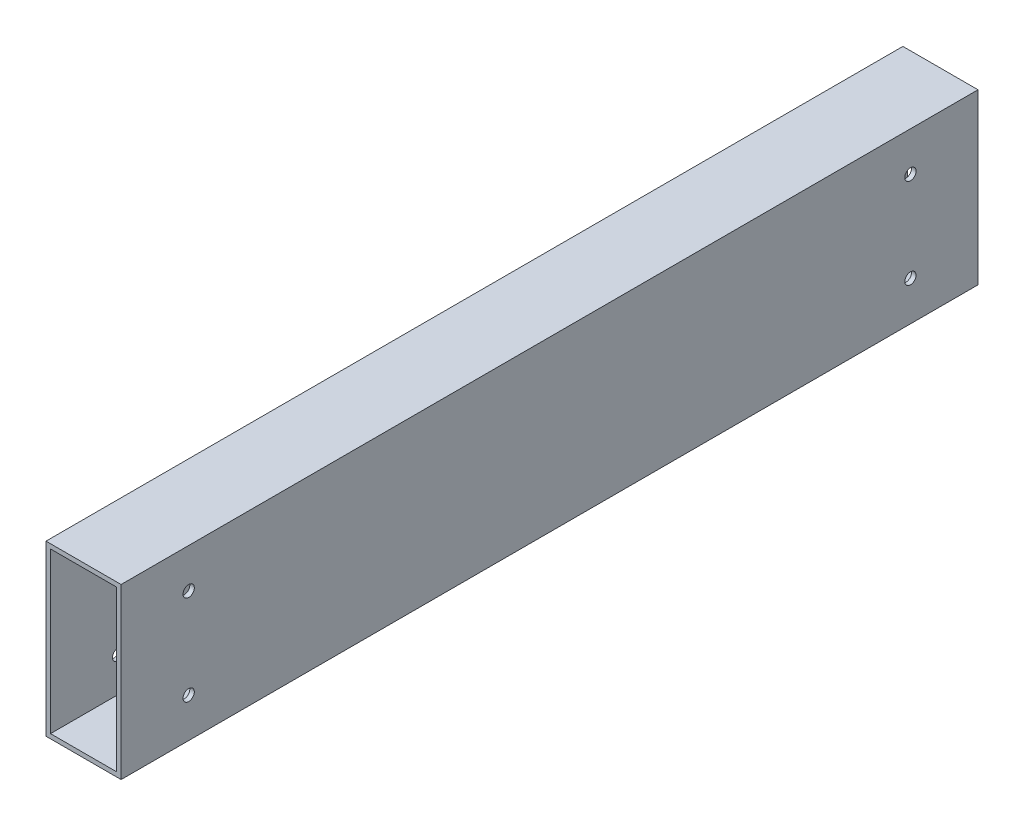
from build123d import *

# Parameters (mm, degrees)
CROQUIS1_W              = 20
CROQUIS1_H              = 45
SALIENTE_EXTRUIR1_DEPTH = 228.2
CROQUIS5_W              = 17.6
CROQUIS5_H              = 42.6
CORTAR_EXTRUIR3_DEPTH   = 228.2
CROQUIS6_R              = 1.5
CORTAR_EXTRUIR4_DEPTH   = 30


with BuildPart() as part:
    # Croquis1 → Saliente-Extruir1 (new body)
    with BuildSketch(Plane.XY):
        Rectangle(CROQUIS1_W, CROQUIS1_H)
    extrude(amount=SALIENTE_EXTRUIR1_DEPTH)

    # Croquis5 → Cortar-Extruir3 (cut)
    with BuildSketch(Plane(origin=(0, 0, 0), x_dir=(-1, 0, 0), z_dir=(0, 0, -1))):
        Rectangle(CROQUIS5_W, CROQUIS5_H)
    extrude(amount=-CORTAR_EXTRUIR3_DEPTH, mode=Mode.SUBTRACT)

    # Croquis6 → Cortar-Extruir4 (cut)
    with BuildSketch(Plane(origin=(10, 0, 0), x_dir=(0, 0, -1), z_dir=(1, 0, 0))):
        with Locations((-210.2, -12)):
            Circle(CROQUIS6_R)
        with Locations((-210.2, 12)):
            Circle(CROQUIS6_R)
        with Locations((-18, 12)):
            Circle(CROQUIS6_R)
        with Locations((-18, -12)):
            Circle(CROQUIS6_R)
    extrude(amount=-CORTAR_EXTRUIR4_DEPTH, mode=Mode.SUBTRACT)


solid = part.part
